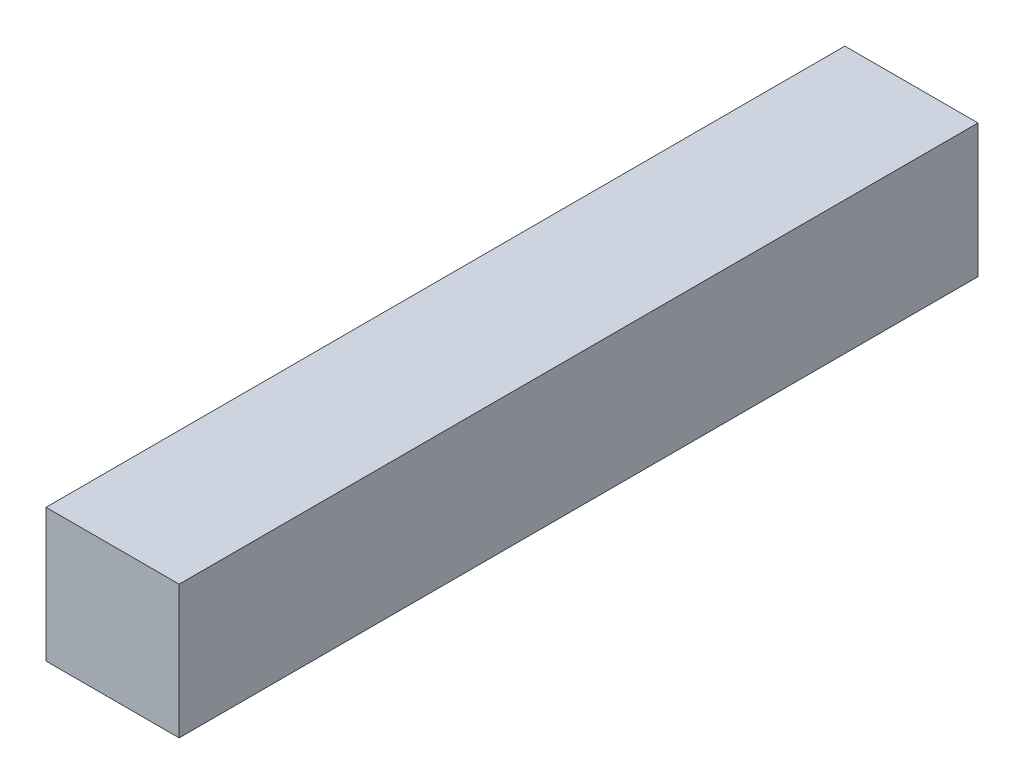
from build123d import *

# Parameters (mm, degrees)
SKETCH1_W           = 12.7
SKETCH1_H           = 12.7
BOSS_EXTRUDE1_DEPTH = 76.2


with BuildPart() as part:
    # Sketch1 → Boss-Extrude1 (new body)
    with BuildSketch(Plane.XY):
        with Locations((6.35, -6.35)):
            Rectangle(SKETCH1_W, SKETCH1_H)
    extrude(amount=BOSS_EXTRUDE1_DEPTH)


solid = part.part
